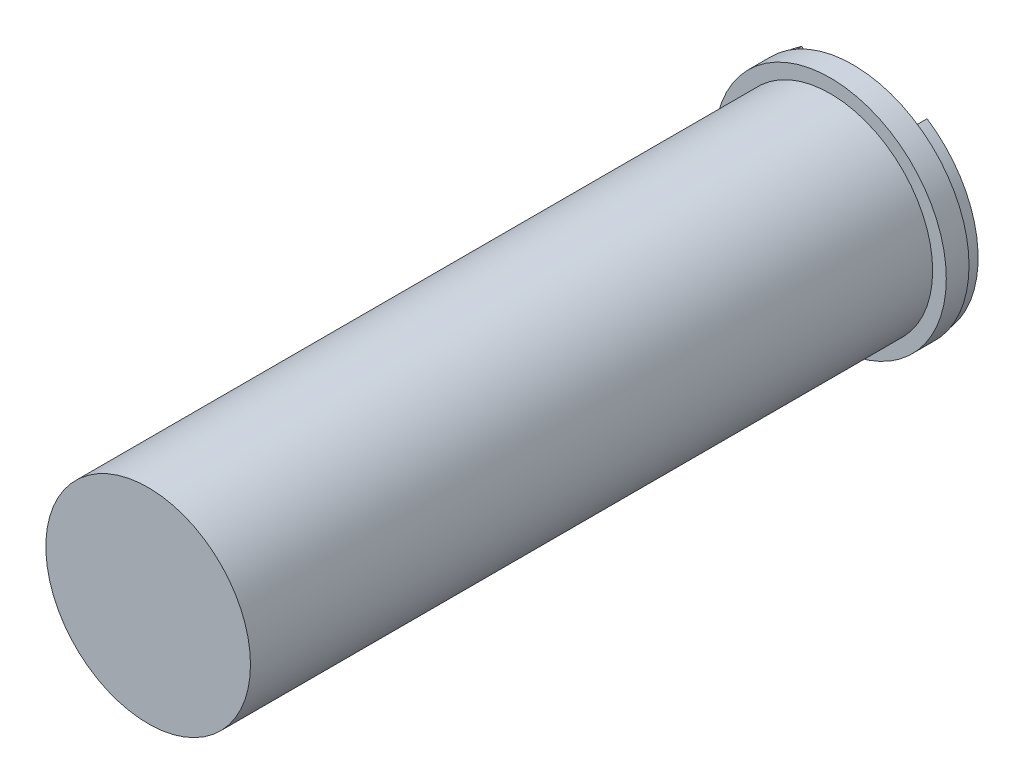
from build123d import *

# Parameters (mm, degrees)
SKETCH_1_R      = 5.1
EXTRUDE_1_DEPTH = 1
SKETCH_2_R      = 4.5
EXTRUDE_2_DEPTH = 30
EXTRUDE_3_DEPTH = 0.5


with BuildPart() as part:
    # Эскиз1 → Бобышка-Вытянуть1 (new body)
    with BuildSketch(Plane.XY):
        Circle(SKETCH_1_R)
    extrude(amount=EXTRUDE_1_DEPTH)

    # Эскиз2 → Бобышка-Вытянуть2 (add)
    with BuildSketch(Plane.XY.offset(1)):
        Circle(SKETCH_2_R)
    extrude(amount=EXTRUDE_2_DEPTH)


with BuildPart() as body_2:
    # Эскиз4 → Бобышка-Вытянуть3 (new body)
    with BuildSketch(Plane(origin=(0, 0, 0), x_dir=(-1, 0, 0), z_dir=(0, 0, -1))):
        with BuildLine():
            Line((2.756994834, 4.171208396), (0, 1.414213562))
            Line((0, 1.414213562), (-2.756994834, 4.171208396))
            ThreePointArc((-2.756994834, 4.171208396), (0, -5), (2.756994834, 4.171208396))
        make_face()
        with BuildLine():
            Line((-3.968626967, 0.5), (-0.5, 0.5))
            Line((-0.5, 0.5), (-2.828427125, 2.828427125))
            ThreePointArc((-2.828427125, 2.828427125), (-3.592405782, 1.759153405), (-3.968626967, 0.5))
        make_face(mode=Mode.SUBTRACT)
        with BuildLine():
            Line((-3.968626967, -0.5), (3.968626967, -0.5))
            ThreePointArc((3.968626967, -0.5), (0, -4), (-3.968626967, -0.5))
        make_face(mode=Mode.SUBTRACT)
        with BuildLine():
            Line((0.5, 0.5), (3.968626967, 0.5))
            ThreePointArc((3.968626967, 0.5), (3.592405782, 1.759153405), (2.828427125, 2.828427125))
            Line((2.828427125, 2.828427125), (0.5, 0.5))
        make_face(mode=Mode.SUBTRACT)
    extrude(amount=EXTRUDE_3_DEPTH)


solid = Compound([part.part, body_2.part])
